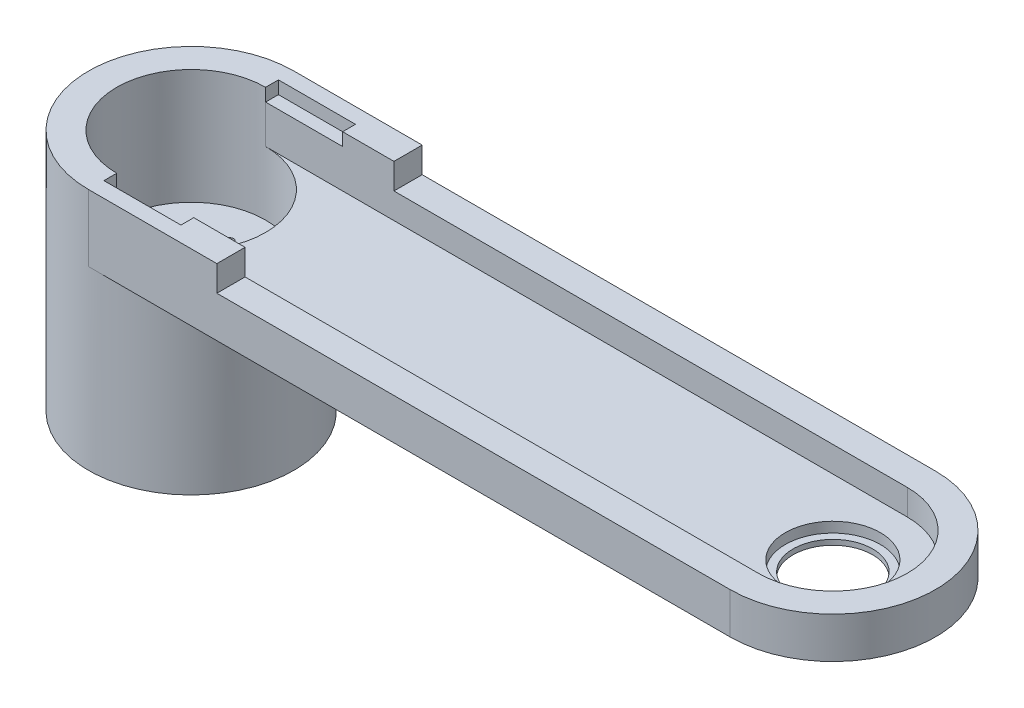
from build123d import *

# Parameters (mm, degrees)
BOSS_EXTRUDE1_DEPTH     = 20
SKETCH2_R               = 40
SKETCH2_R_2             = 29
BOSS_EXTRUDE2_DEPTH     = 24.8
SKETCH3_R               = 40
BOSS_EXTRUDE3_DEPTH     = 5
BOSS_EXTRUDE4_DEPTH     = 6
SKETCH5_R               = 1.5
CUT_EXTRUDE1_DEPTH      = 45.8
CUT_EXTRUDE1_DEPTH_BACK = 6
SKETCH6_W               = 30
SKETCH6_H               = 5
CUT_EXTRUDE2_DEPTH      = 34
CUT_EXTRUDE2_DEPTH_BACK = 34
SKETCH7_R               = 18.5
SKETCH7_R_2             = 15.5
CUT_EXTRUDE3_DEPTH      = 4
SKETCH7_2_R             = 15.5
CUT_EXTRUDE4_DEPTH      = 21
CUT_EXTRUDE4_DEPTH_BACK = 30.8
CUT_EXTRUDE5_DEPTH      = 10
SKETCH10_R              = 40
SKETCH10_R_2            = 1.5
BOSS_EXTRUDE5_DEPTH     = 45
SKETCH11_R              = 8.5
CUT_EXTRUDE6_DEPTH      = 6


with BuildPart() as part:
    # Sketch1 → Boss-Extrude1 (new body)
    with BuildSketch(Plane(origin=(0, 0, 0), x_dir=(1, 0, 0), z_dir=(0, 1, 0))):
        with BuildLine():
            Line((0, -40), (250, -40))
            ThreePointArc((250, -40), (290, 0), (250, 40))
            Line((250, 40), (0, 40))
            ThreePointArc((0, 40), (-40, 0), (0, -40))
        make_face()
        with BuildLine():
            Line((0, 29), (250, 29))
            ThreePointArc((250, 29), (279, 0), (250, -29))
            Line((250, -29), (0, -29))
            ThreePointArc((0, -29), (-29, 0), (0, 29))
        make_face(mode=Mode.SUBTRACT)
    extrude(amount=BOSS_EXTRUDE1_DEPTH)

    # Sketch2 → Boss-Extrude2 (add)
    with BuildSketch(Plane.XZ):
        Circle(SKETCH2_R)
        Circle(SKETCH2_R_2, mode=Mode.SUBTRACT)
    extrude(amount=BOSS_EXTRUDE2_DEPTH)

    # Sketch3 → Boss-Extrude3 (add)
    with BuildSketch(Plane.XZ.offset(24.8)):
        Circle(SKETCH3_R)
    extrude(amount=BOSS_EXTRUDE3_DEPTH)

    # Sketch4 → Boss-Extrude4 (add)
    with BuildSketch(Plane.XZ):
        with BuildLine():
            Line((250, -40), (0, -40))
            ThreePointArc((0, -40), (14.832396974, -37.148351242), (27.549954628, -29))
            ThreePointArc((27.549954628, -29), (40, 0), (27.549954628, 29))
            ThreePointArc((27.549954628, 29), (14.832396974, 37.148351242), (0, 40))
            Line((0, 40), (250, 40))
            ThreePointArc((250, 40), (290, 0), (250, -40))
        make_face()
    extrude(amount=BOSS_EXTRUDE4_DEPTH)

    # Sketch5 → Cut-Extrude1 (cut, two sides)
    with BuildSketch(Plane(origin=(0, -24.8, 0), x_dir=(1, 0, 0), z_dir=(0, 1, 0))) as cut_extrude1_sk:
        with Locations((0, 15)):
            Circle(SKETCH5_R)
        with Locations((15, 0)):
            Circle(SKETCH5_R)
        with Locations((0, -15)):
            Circle(SKETCH5_R)
        with Locations((-15, 0)):
            Circle(SKETCH5_R)
    extrude(amount=CUT_EXTRUDE1_DEPTH, mode=Mode.SUBTRACT)
    extrude(cut_extrude1_sk.sketch, amount=-CUT_EXTRUDE1_DEPTH_BACK, mode=Mode.SUBTRACT)

    # Sketch6 → Cut-Extrude2 (cut, two sides)
    with BuildSketch(Plane.XY) as cut_extrude2_sk:
        with Locations((15, 17.5)):
            Rectangle(SKETCH6_W, SKETCH6_H)
    extrude(amount=CUT_EXTRUDE2_DEPTH, mode=Mode.SUBTRACT)
    extrude(cut_extrude2_sk.sketch, amount=-CUT_EXTRUDE2_DEPTH_BACK, mode=Mode.SUBTRACT)

    # Sketch7 → Cut-Extrude3 (cut)
    with BuildSketch(Plane(origin=(0, 0, 0), x_dir=(1, 0, 0), z_dir=(0, 1, 0))):
        with Locations((250, 0)):
            Circle(SKETCH7_R)
        with Locations((250, 0)):
            Circle(SKETCH7_R_2, mode=Mode.SUBTRACT)
    extrude(amount=-CUT_EXTRUDE3_DEPTH, mode=Mode.SUBTRACT)

    # Sketch7_2 → Cut-Extrude4 (cut, two sides)
    with BuildSketch(Plane(origin=(0, 0, 0), x_dir=(1, 0, 0), z_dir=(0, 1, 0))) as cut_extrude4_sk:
        with Locations((250, 0)):
            Circle(SKETCH7_2_R)
    extrude(amount=CUT_EXTRUDE4_DEPTH, mode=Mode.SUBTRACT)
    extrude(cut_extrude4_sk.sketch, amount=-CUT_EXTRUDE4_DEPTH_BACK, mode=Mode.SUBTRACT)

    # Sketch9 → Cut-Extrude5 (cut)
    with BuildSketch(Plane(origin=(0, 20, 0), x_dir=(1, 0, 0), z_dir=(0, 1, 0))):
        with BuildLine():
            Line((50, -40), (250, -40))
            ThreePointArc((250, -40), (290, 0), (250, 40))
            Line((250, 40), (50, 40))
            Line((50, 40), (50, -40))
        make_face()
    extrude(amount=-CUT_EXTRUDE5_DEPTH, mode=Mode.SUBTRACT)

    # Sketch10 → Boss-Extrude5 (add)
    with BuildSketch(Plane.XZ.offset(29.8)):
        Circle(SKETCH10_R)
        with Locations((-15, 0)):
            Circle(SKETCH10_R_2, mode=Mode.SUBTRACT)
        with Locations((0, -15)):
            Circle(SKETCH10_R_2, mode=Mode.SUBTRACT)
        with Locations((15, 0)):
            Circle(SKETCH10_R_2, mode=Mode.SUBTRACT)
        with Locations((0, 15)):
            Circle(SKETCH10_R_2, mode=Mode.SUBTRACT)
    extrude(amount=BOSS_EXTRUDE5_DEPTH)

    # Sketch11 → Cut-Extrude6 (cut)
    with BuildSketch(Plane.XZ.offset(74.8)):
        Circle(SKETCH11_R)
    extrude(amount=-CUT_EXTRUDE6_DEPTH, mode=Mode.SUBTRACT)


solid = part.part
